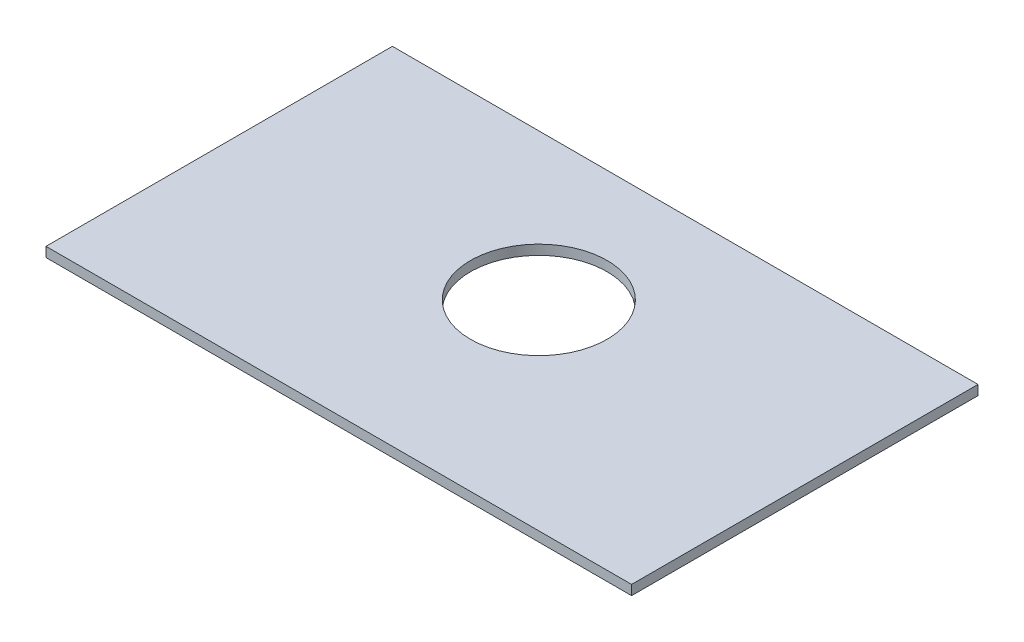
from build123d import *

# Parameters (mm, degrees)
SKETCH1_W           = 180
SKETCH1_H           = 106.48
SKETCH1_R           = 21
BOSS_EXTRUDE1_DEPTH = 3


with BuildPart() as part:
    # Sketch1 → Boss-Extrude1 (new body)
    with BuildSketch(Plane(origin=(0, 0, 0), x_dir=(1, 0, 0), z_dir=(0, 1, 0))):
        with Locations((39.712051829, 46.288013332)):
            Rectangle(SKETCH1_W, SKETCH1_H)
        with Locations((39.712051829, 54.528013332)):
            Circle(SKETCH1_R, mode=Mode.SUBTRACT)
    extrude(amount=BOSS_EXTRUDE1_DEPTH)


solid = part.part
